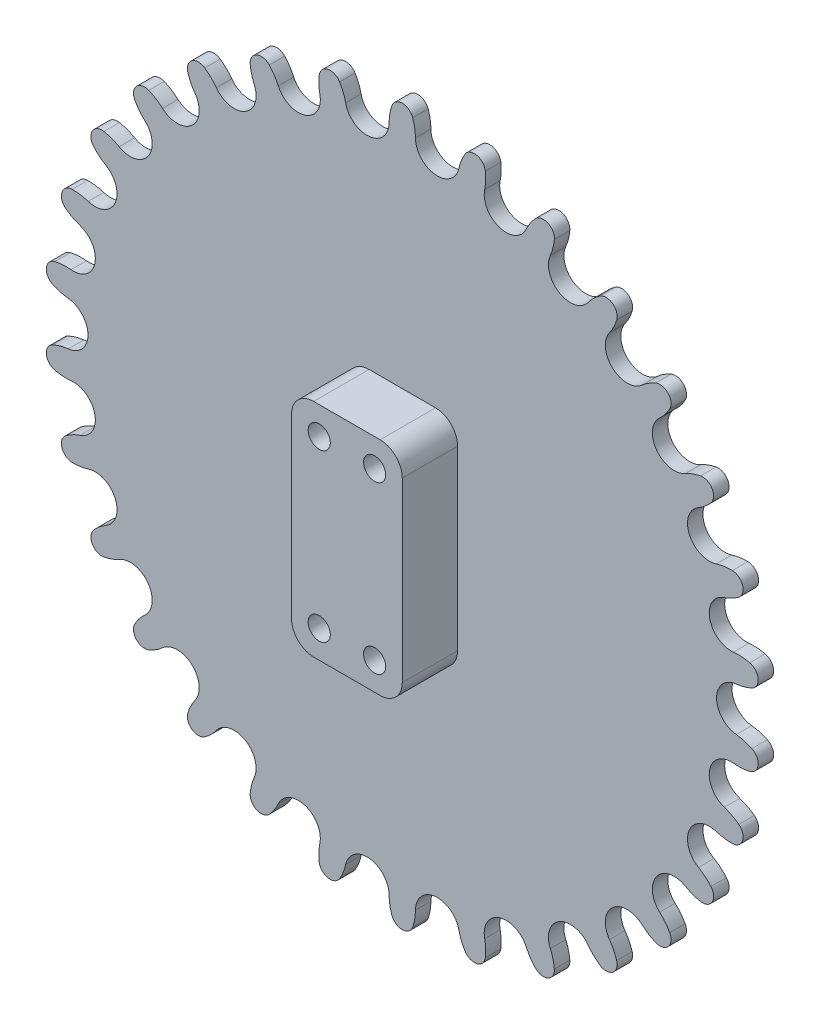
from build123d import *

# Parameters (mm, degrees)
BOSS_EXTRUDE1_DEPTH = 2.794
SKETCH5_R           = 4
BOSS_EXTRUDE3_DEPTH = 32.206
BOSS_EXTRUDE4_DEPTH = 10
SKETCH6_R           = 2
CUT_EXTRUDE1_DEPTH  = 46
SKETCH7_R           = 5
BOSS_EXTRUDE5_DEPTH = 19


with BuildPart() as part:
    # Sketch2 → Boss-Extrude1 (new body)
    with BuildSketch(Plane.XY):
        with BuildLine():
            ThreePointArc((-8.73125, 0), (-8.606730181, 1.469327109), (-8.236722377, 2.896744905))
            ThreePointArc((-8.236722377, 2.896744905), (-6.35, 4.233209924), (-4.463277623, 2.896744905))
            ThreePointArc((-4.463277623, 2.896744905), (-4.093269819, 1.469327109), (-3.96875, 0))
            ThreePointArc((-3.96875, 0), (-2.949356026, -2.655612094), (-0.414847339, -3.947008772))
            ThreePointArc((-0.414847339, -3.947008772), (2.33277272, -3.210786196), (3.88202329, -0.825149523))
            ThreePointArc((3.88202329, -0.825149523), (4.309312336, 0.586180138), (4.96801143, 1.905476482))
            ThreePointArc((4.96801143, 1.905476482), (7.091371097, 2.820464893), (8.658997362, 1.120933203))
            ThreePointArc((8.658997362, 1.120933203), (8.72414276, -0.352221038), (8.540451239, -1.81532895))
            ThreePointArc((8.540451239, -1.81532895), (8.985436208, -4.624853473), (11.196063333, -6.414984022))
            ThreePointArc((11.196063333, -6.414984022), (14.036710582, -6.266112008), (16.048108064, -4.254714526))
            ThreePointArc((16.048108064, -4.254714526), (16.759491755, -2.963064192), (17.678093827, -1.809548881))
            ThreePointArc((17.678093827, -1.809548881), (19.945289779, -1.35602646), (21.125307141, -3.344347133))
            ThreePointArc((21.125307141, -3.344347133), (20.882742967, -4.798853909), (20.398868306, -6.191797788))
            ThreePointArc((20.398868306, -6.191797788), (20.249996292, -9.032445037), (22.040126841, -11.243072162))
            ThreePointArc((22.040126841, -11.243072162), (24.849651364, -11.688057131), (27.235288038, -10.13880656))
            ThreePointArc((27.235288038, -10.13880656), (28.199675493, -9.023286872), (29.338033224, -8.085966747))
            ThreePointArc((29.338033224, -8.085966747), (31.649978119, -8.113731424), (32.390814157, -10.303941924))
            ThreePointArc((32.390814157, -10.303941924), (31.851141629, -11.67623231), (31.088231474, -12.938133825))
            ThreePointArc((31.088231474, -12.938133825), (30.352008898, -15.685753883), (31.643405576, -18.220262571))
            ThreePointArc((31.643405576, -18.220262571), (34.29901767, -19.239656545), (36.954629764, -18.220262571))
            ThreePointArc((36.954629764, -18.220262571), (38.129872624, -17.32962709), (39.438234319, -16.64946754))
            ThreePointArc((39.438234319, -16.64946754), (41.69388507, -17.157305863), (41.963161696, -19.453683483))
            ThreePointArc((41.963161696, -19.453683483), (41.149967093, -20.683781803), (40.141364277, -21.759489802))
            ThreePointArc((40.141364277, -21.759489802), (38.849967598, -24.29399849), (39.586190174, -27.041618548))
            ThreePointArc((39.586190174, -27.041618548), (41.971826848, -28.590869119), (44.781351371, -28.145884149))
            ThreePointArc((44.781351371, -28.145884149), (46.116085883, -27.519057921), (47.537269859, -27.125785181))
            ThreePointArc((47.537269859, -27.125785181), (49.638043704, -28.09150218), (49.423992236, -30.393684198))
            ThreePointArc((49.423992236, -30.393684198), (48.372816064, -31.427829254), (47.162601371, -32.270330135))
            ThreePointArc((47.162601371, -32.270330135), (45.372470822, -34.48095726), (45.521342836, -37.321604508))
            ThreePointArc((45.521342836, -37.321604508), (47.532740318, -39.333001991), (50.373387567, -39.481874005))
            ThreePointArc((50.373387567, -39.481874005), (51.809279429, -39.146252343), (53.281173125, -39.057054319))
            ThreePointArc((53.281173125, -39.057054319), (55.135256168, -40.438443528), (54.447231681, -42.645813542))
            ThreePointArc((54.447231681, -42.645813542), (53.204015385, -43.438808232), (51.845081003, -44.011280664))
            ThreePointArc((51.845081003, -44.011280664), (49.634453878, -45.801411213), (49.189468909, -48.610935736))
            ThreePointArc((49.189468909, -48.610935736), (50.738719479, -50.99657241), (53.486339538, -51.732794985))
            ThreePointArc((53.486339538, -51.732794985), (54.960633385, -51.703046167), (56.418907984, -51.921821241))
            ThreePointArc((56.418907984, -51.921821241), (57.945267898, -53.658509321), (56.813340365, -55.67459467))
            ThreePointArc((56.813340365, -55.67459467), (55.432418461, -56.191781321), (53.984156344, -56.469205512))
            ThreePointArc((53.984156344, -56.469205512), (51.449647657, -57.76060219), (50.430253683, -60.416214284))
            ThreePointArc((50.430253683, -60.416214284), (51.449647657, -63.071826378), (53.984156344, -64.363223057))
            ThreePointArc((53.984156344, -64.363223057), (55.432418461, -64.640647248), (56.813340365, -65.157833899))
            ThreePointArc((56.813340365, -65.157833899), (57.945267898, -67.173919248), (56.418907984, -68.910607328))
            ThreePointArc((56.418907984, -68.910607328), (54.960633385, -69.129382402), (53.486339538, -69.099633583))
            ThreePointArc((53.486339538, -69.099633583), (50.738719479, -69.835856159), (49.189468909, -72.221492833))
            ThreePointArc((49.189468909, -72.221492833), (49.634453878, -75.031017355), (51.845081003, -76.821147905))
            ThreePointArc((51.845081003, -76.821147905), (53.204015385, -77.393620337), (54.447231681, -78.186615027))
            ThreePointArc((54.447231681, -78.186615027), (55.135256168, -80.393985041), (53.281173125, -81.775374249))
            ThreePointArc((53.281173125, -81.775374249), (51.809279429, -81.686176225), (50.373387567, -81.350554563))
            ThreePointArc((50.373387567, -81.350554563), (47.532740318, -81.499426577), (45.521342836, -83.51082406))
            ThreePointArc((45.521342836, -83.51082406), (45.372470822, -86.351471309), (47.162601371, -88.562098434))
            ThreePointArc((47.162601371, -88.562098434), (48.372816064, -89.404599315), (49.423992236, -90.438744371))
            ThreePointArc((49.423992236, -90.438744371), (49.638043704, -92.740926388), (47.537269859, -93.706643388))
            ThreePointArc((47.537269859, -93.706643388), (46.116085883, -93.313370647), (44.781351371, -92.686544419))
            ThreePointArc((44.781351371, -92.686544419), (41.971826848, -92.24155945), (39.586190174, -93.79081002))
            ThreePointArc((39.586190174, -93.79081002), (38.849967598, -96.538430079), (40.141364277, -99.072938767))
            ThreePointArc((40.141364277, -99.072938767), (41.149967093, -100.148646765), (41.963161696, -101.378745086))
            ThreePointArc((41.963161696, -101.378745086), (41.69388507, -103.675122705), (39.438234319, -104.182961029))
            ThreePointArc((39.438234319, -104.182961029), (38.129872624, -103.502801478), (36.954629764, -102.612165998))
            ThreePointArc((36.954629764, -102.612165998), (34.29901767, -101.592772024), (31.643405576, -102.612165998))
            ThreePointArc((31.643405576, -102.612165998), (30.352008898, -105.146674685), (31.088231474, -107.894294744))
            ThreePointArc((31.088231474, -107.894294744), (31.851141629, -109.156196259), (32.390814157, -110.528486645))
            ThreePointArc((32.390814157, -110.528486645), (31.649978119, -112.718697145), (29.338033224, -112.746461821))
            ThreePointArc((29.338033224, -112.746461821), (28.199675493, -111.809141697), (27.235288038, -110.693622008))
            ThreePointArc((27.235288038, -110.693622008), (24.849651364, -109.144371438), (22.040126841, -109.589356407))
            ThreePointArc((22.040126841, -109.589356407), (20.249996292, -111.799983532), (20.398868306, -114.64063078))
            ThreePointArc((20.398868306, -114.64063078), (20.882742967, -116.03357466), (21.125307141, -117.488081436))
            ThreePointArc((21.125307141, -117.488081436), (19.945289779, -119.476402109), (17.678093827, -119.022879688))
            ThreePointArc((17.678093827, -119.022879688), (16.759491755, -117.869364376), (16.048108064, -116.577714043))
            ThreePointArc((16.048108064, -116.577714043), (14.036710582, -114.56631656), (11.196063333, -114.417444546))
            ThreePointArc((11.196063333, -114.417444546), (8.985436208, -116.207575095), (8.540451239, -119.017099618))
            ThreePointArc((8.540451239, -119.017099618), (8.72414276, -120.480207531), (8.658997362, -121.953361772))
            ThreePointArc((8.658997362, -121.953361772), (7.091371097, -123.652893462), (4.96801143, -122.737905051))
            ThreePointArc((4.96801143, -122.737905051), (4.309312336, -121.418608706), (3.88202329, -120.007279046))
            ThreePointArc((3.88202329, -120.007279046), (2.33277272, -117.621642372), (-0.414847339, -116.885419796))
            ThreePointArc((-0.414847339, -116.885419796), (-2.949356026, -118.176816475), (-3.96875, -120.832428569))
            ThreePointArc((-3.96875, -120.832428569), (-4.093269819, -122.301755678), (-4.463277623, -123.729173474))
            ThreePointArc((-4.463277623, -123.729173474), (-6.35, -125.065638492), (-8.236722377, -123.729173474))
            ThreePointArc((-8.236722377, -123.729173474), (-8.606730181, -122.301755678), (-8.73125, -120.832428569))
            ThreePointArc((-8.73125, -120.832428569), (-9.750643974, -118.176816475), (-12.285152661, -116.885419796))
            ThreePointArc((-12.285152661, -116.885419796), (-15.03277272, -117.621642372), (-16.58202329, -120.007279046))
            ThreePointArc((-16.58202329, -120.007279046), (-17.009312336, -121.418608706), (-17.66801143, -122.737905051))
            ThreePointArc((-17.66801143, -122.737905051), (-19.791371097, -123.652893462), (-21.358997362, -121.953361772))
            ThreePointArc((-21.358997362, -121.953361772), (-21.42414276, -120.480207531), (-21.240451239, -119.017099618))
            ThreePointArc((-21.240451239, -119.017099618), (-21.685436208, -116.207575095), (-23.896063333, -114.417444546))
            ThreePointArc((-23.896063333, -114.417444546), (-26.736710582, -114.56631656), (-28.748108064, -116.577714043))
            ThreePointArc((-28.748108064, -116.577714043), (-29.459491755, -117.869364376), (-30.378093827, -119.022879688))
            ThreePointArc((-30.378093827, -119.022879688), (-32.645289779, -119.476402109), (-33.825307141, -117.488081436))
            ThreePointArc((-33.825307141, -117.488081436), (-33.582742967, -116.03357466), (-33.098868306, -114.64063078))
            ThreePointArc((-33.098868306, -114.64063078), (-32.949996292, -111.799983532), (-34.740126841, -109.589356407))
            ThreePointArc((-34.740126841, -109.589356407), (-37.549651364, -109.144371438), (-39.935288038, -110.693622008))
            ThreePointArc((-39.935288038, -110.693622008), (-40.899675493, -111.809141697), (-42.038033224, -112.746461821))
            ThreePointArc((-42.038033224, -112.746461821), (-44.349978119, -112.718697145), (-45.090814157, -110.528486645))
            ThreePointArc((-45.090814157, -110.528486645), (-44.551141629, -109.156196259), (-43.788231474, -107.894294744))
            ThreePointArc((-43.788231474, -107.894294744), (-43.052008898, -105.146674685), (-44.343405576, -102.612165998))
            ThreePointArc((-44.343405576, -102.612165998), (-46.99901767, -101.592772024), (-49.654629764, -102.612165998))
            ThreePointArc((-49.654629764, -102.612165998), (-50.829872624, -103.502801478), (-52.138234319, -104.182961029))
            ThreePointArc((-52.138234319, -104.182961029), (-54.39388507, -103.675122705), (-54.663161696, -101.378745086))
            ThreePointArc((-54.663161696, -101.378745086), (-53.849967093, -100.148646765), (-52.841364277, -99.072938767))
            ThreePointArc((-52.841364277, -99.072938767), (-51.549967598, -96.538430079), (-52.286190174, -93.79081002))
            ThreePointArc((-52.286190174, -93.79081002), (-54.671826848, -92.24155945), (-57.481351371, -92.686544419))
            ThreePointArc((-57.481351371, -92.686544419), (-58.816085883, -93.313370647), (-60.237269859, -93.706643388))
            ThreePointArc((-60.237269859, -93.706643388), (-62.338043704, -92.740926388), (-62.123992236, -90.438744371))
            ThreePointArc((-62.123992236, -90.438744371), (-61.072816064, -89.404599315), (-59.862601371, -88.562098434))
            ThreePointArc((-59.862601371, -88.562098434), (-58.072470822, -86.351471309), (-58.221342836, -83.51082406))
            ThreePointArc((-58.221342836, -83.51082406), (-60.232740318, -81.499426577), (-63.073387567, -81.350554563))
            ThreePointArc((-63.073387567, -81.350554563), (-64.509279429, -81.686176225), (-65.981173125, -81.775374249))
            ThreePointArc((-65.981173125, -81.775374249), (-67.835256168, -80.393985041), (-67.147231681, -78.186615027))
            ThreePointArc((-67.147231681, -78.186615027), (-65.904015385, -77.393620337), (-64.545081003, -76.821147905))
            ThreePointArc((-64.545081003, -76.821147905), (-62.334453878, -75.031017355), (-61.889468909, -72.221492833))
            ThreePointArc((-61.889468909, -72.221492833), (-63.438719479, -69.835856159), (-66.186339538, -69.099633583))
            ThreePointArc((-66.186339538, -69.099633583), (-67.660633385, -69.129382402), (-69.118907984, -68.910607328))
            ThreePointArc((-69.118907984, -68.910607328), (-70.645267898, -67.173919248), (-69.513340365, -65.157833899))
            ThreePointArc((-69.513340365, -65.157833899), (-68.132418461, -64.640647248), (-66.684156344, -64.363223057))
            ThreePointArc((-66.684156344, -64.363223057), (-64.149647657, -63.071826378), (-63.130253683, -60.416214284))
            ThreePointArc((-63.130253683, -60.416214284), (-64.149647657, -57.76060219), (-66.684156344, -56.469205512))
            ThreePointArc((-66.684156344, -56.469205512), (-68.132418461, -56.191781321), (-69.513340365, -55.67459467))
            ThreePointArc((-69.513340365, -55.67459467), (-70.645267898, -53.658509321), (-69.118907984, -51.921821241))
            ThreePointArc((-69.118907984, -51.921821241), (-67.660633385, -51.703046167), (-66.186339538, -51.732794985))
            ThreePointArc((-66.186339538, -51.732794985), (-63.438719479, -50.99657241), (-61.889468909, -48.610935736))
            ThreePointArc((-61.889468909, -48.610935736), (-62.334453878, -45.801411213), (-64.545081003, -44.011280664))
            ThreePointArc((-64.545081003, -44.011280664), (-65.904015385, -43.438808232), (-67.147231681, -42.645813542))
            ThreePointArc((-67.147231681, -42.645813542), (-67.835256168, -40.438443528), (-65.981173125, -39.057054319))
            ThreePointArc((-65.981173125, -39.057054319), (-64.509279429, -39.146252343), (-63.073387567, -39.481874005))
            ThreePointArc((-63.073387567, -39.481874005), (-60.232740318, -39.333001991), (-58.221342836, -37.321604508))
            ThreePointArc((-58.221342836, -37.321604508), (-58.072470822, -34.48095726), (-59.862601371, -32.270330135))
            ThreePointArc((-59.862601371, -32.270330135), (-61.072816064, -31.427829254), (-62.123992236, -30.393684198))
            ThreePointArc((-62.123992236, -30.393684198), (-62.338043704, -28.09150218), (-60.237269859, -27.125785181))
            ThreePointArc((-60.237269859, -27.125785181), (-58.816085883, -27.519057921), (-57.481351371, -28.145884149))
            ThreePointArc((-57.481351371, -28.145884149), (-54.671826848, -28.590869119), (-52.286190174, -27.041618548))
            ThreePointArc((-52.286190174, -27.041618548), (-51.549967598, -24.29399849), (-52.841364277, -21.759489802))
            ThreePointArc((-52.841364277, -21.759489802), (-53.849967093, -20.683781803), (-54.663161696, -19.453683483))
            ThreePointArc((-54.663161696, -19.453683483), (-54.39388507, -17.157305863), (-52.138234319, -16.64946754))
            ThreePointArc((-52.138234319, -16.64946754), (-50.829872624, -17.32962709), (-49.654629764, -18.220262571))
            ThreePointArc((-49.654629764, -18.220262571), (-46.99901767, -19.239656545), (-44.343405576, -18.220262571))
            ThreePointArc((-44.343405576, -18.220262571), (-43.052008898, -15.685753883), (-43.788231474, -12.938133825))
            ThreePointArc((-43.788231474, -12.938133825), (-44.551141629, -11.67623231), (-45.090814157, -10.303941924))
            ThreePointArc((-45.090814157, -10.303941924), (-44.349978119, -8.113731424), (-42.038033224, -8.085966747))
            ThreePointArc((-42.038033224, -8.085966747), (-40.899675493, -9.023286872), (-39.935288038, -10.13880656))
            ThreePointArc((-39.935288038, -10.13880656), (-37.549651364, -11.688057131), (-34.740126841, -11.243072162))
            ThreePointArc((-34.740126841, -11.243072162), (-32.949996292, -9.032445037), (-33.098868306, -6.191797788))
            ThreePointArc((-33.098868306, -6.191797788), (-33.582742967, -4.798853909), (-33.825307141, -3.344347133))
            ThreePointArc((-33.825307141, -3.344347133), (-32.645289779, -1.35602646), (-30.378093827, -1.809548881))
            ThreePointArc((-30.378093827, -1.809548881), (-29.459491755, -2.963064192), (-28.748108064, -4.254714526))
            ThreePointArc((-28.748108064, -4.254714526), (-26.736710582, -6.266112008), (-23.896063333, -6.414984022))
            ThreePointArc((-23.896063333, -6.414984022), (-21.685436208, -4.624853473), (-21.240451239, -1.81532895))
            ThreePointArc((-21.240451239, -1.81532895), (-21.42414276, -0.352221038), (-21.358997362, 1.120933203))
            ThreePointArc((-21.358997362, 1.120933203), (-19.791371097, 2.820464893), (-17.66801143, 1.905476482))
            ThreePointArc((-17.66801143, 1.905476482), (-17.009312336, 0.586180138), (-16.58202329, -0.825149523))
            ThreePointArc((-16.58202329, -0.825149523), (-15.03277272, -3.210786196), (-12.285152661, -3.947008772))
            ThreePointArc((-12.285152661, -3.947008772), (-9.750643974, -2.655612094), (-8.73125, 0))
        make_face()
    extrude(amount=BOSS_EXTRUDE1_DEPTH)

    # Sketch5 → Boss-Extrude3 (add)
    with BuildSketch(Plane(origin=(0, 0, 0), x_dir=(-1, 0, 0), z_dir=(0, 0, -1))):
        with Locations((6.35, -60.416214284)):
            Circle(SKETCH5_R)
    extrude(amount=BOSS_EXTRUDE3_DEPTH)

    # Sketch3 → Boss-Extrude4 (add)
    with BuildSketch(Plane.XY.offset(2.794)):
        with BuildLine():
            Line((-0.35, -40.416214284), (-12.35, -40.416214284))
            ThreePointArc((-12.35, -40.416214284), (-15.178427125, -41.58778716), (-16.35, -44.416214284))
            Line((-16.35, -44.416214284), (-16.35, -76.416214284))
            ThreePointArc((-16.35, -76.416214284), (-15.178427125, -79.244641409), (-12.35, -80.416214284))
            Line((-12.35, -80.416214284), (-0.35, -80.416214284))
            ThreePointArc((-0.35, -80.416214284), (2.478427125, -79.244641409), (3.65, -76.416214284))
            Line((3.65, -76.416214284), (3.65, -44.416214284))
            ThreePointArc((3.65, -44.416214284), (2.478427125, -41.58778716), (-0.35, -40.416214284))
        make_face()
    extrude(amount=BOSS_EXTRUDE4_DEPTH)

    # Sketch6 → Cut-Extrude1 (cut, through all)
    with BuildSketch(Plane.XY.offset(12.794)):
        with Locations((-11.35, -45.416214284)):
            Circle(SKETCH6_R)
        with Locations((-11.35, -75.416214284)):
            Circle(SKETCH6_R)
        with Locations((-1.35, -75.416214284)):
            Circle(SKETCH6_R)
        with Locations((-1.35, -45.416214284)):
            Circle(SKETCH6_R)
    extrude(amount=-CUT_EXTRUDE1_DEPTH, mode=Mode.SUBTRACT)

    # Sketch7 → Boss-Extrude5 (add)
    with BuildSketch(Plane.XY.offset(2.794)):
        with Locations((-6.35, -60.416214284)):
            Circle(SKETCH7_R)
    extrude(amount=-BOSS_EXTRUDE5_DEPTH)


solid = part.part
